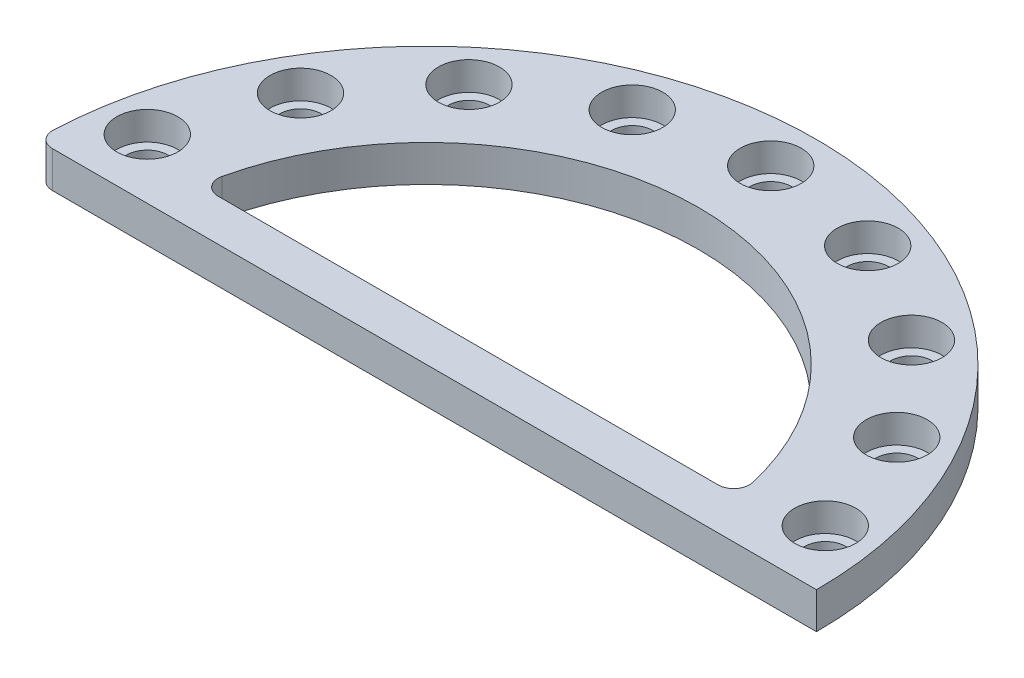
from build123d import *

# Parameters (mm, degrees)
SKETCH1_R           = 75
BOSS_EXTRUDE1_DEPTH = 7
SKETCH2_R           = 5.875
CUT_EXTRUDE1_DEPTH  = 5.45
SKETCH3_R           = 4
CUT_EXTRUDE2_DEPTH  = 2.55
CIRPATTERN1_COUNT   = 18
FILLET1_R           = 3


with BuildPart() as part:
    # Sketch1 → Boss-Extrude1 (new body)
    with BuildSketch(Plane(origin=(0, 0, 0), x_dir=(1, 0, 0), z_dir=(0, 1, 0))):
        Circle(SKETCH1_R)
        with BuildLine():
            Line((-51.709821359, 8), (51.709821359, 8))
            ThreePointArc((51.709821359, 8), (0, 52.325), (-51.709821359, 8))
        make_face(mode=Mode.SUBTRACT)
    extrude(amount=BOSS_EXTRUDE1_DEPTH)

    # Sketch2 → Cut-Extrude1 (cut)
    with BuildSketch(Plane(origin=(0, 7, 0), x_dir=(1, 0, 0), z_dir=(0, 1, 0))):
        with Locations((0, 66.2)):
            Circle(SKETCH2_R)
    cut_extrude1 = extrude(amount=-CUT_EXTRUDE1_DEPTH, mode=Mode.SUBTRACT)

    # Sketch3 → Cut-Extrude2 (cut, through all)
    with BuildSketch(Plane(origin=(0, 1.55, 0), x_dir=(1, 0, 0), z_dir=(0, 1, 0))):
        with Locations((0, 66.2)):
            Circle(SKETCH3_R)
    cut_extrude2 = extrude(amount=-CUT_EXTRUDE2_DEPTH, mode=Mode.SUBTRACT)

    # CirPattern1: Cut-Extrude1, Cut-Extrude2 ×18 about axis
    cirpattern1_axis = Axis((0, 0, 0), (0, 1, 0))
    for i in range(1, CIRPATTERN1_COUNT):
        add(cut_extrude1.rotate(cirpattern1_axis, i * 360 / CIRPATTERN1_COUNT), mode=Mode.SUBTRACT)
        add(cut_extrude2.rotate(cirpattern1_axis, i * 360 / CIRPATTERN1_COUNT), mode=Mode.SUBTRACT)

    # Split1
    split(bisect_by=Plane.XY, keep=Keep.BOTTOM)

    # Fillet1
    fillet1_edges = [part.edges().sort_by_distance(p)[0] for p in [
        (51.709821359, 3.5, -8),
        (-51.709821359, 3.5, -8),
        (-75, 3.5, 0),
    ]]
    fillet(fillet1_edges, radius=FILLET1_R)


solid = part.part
